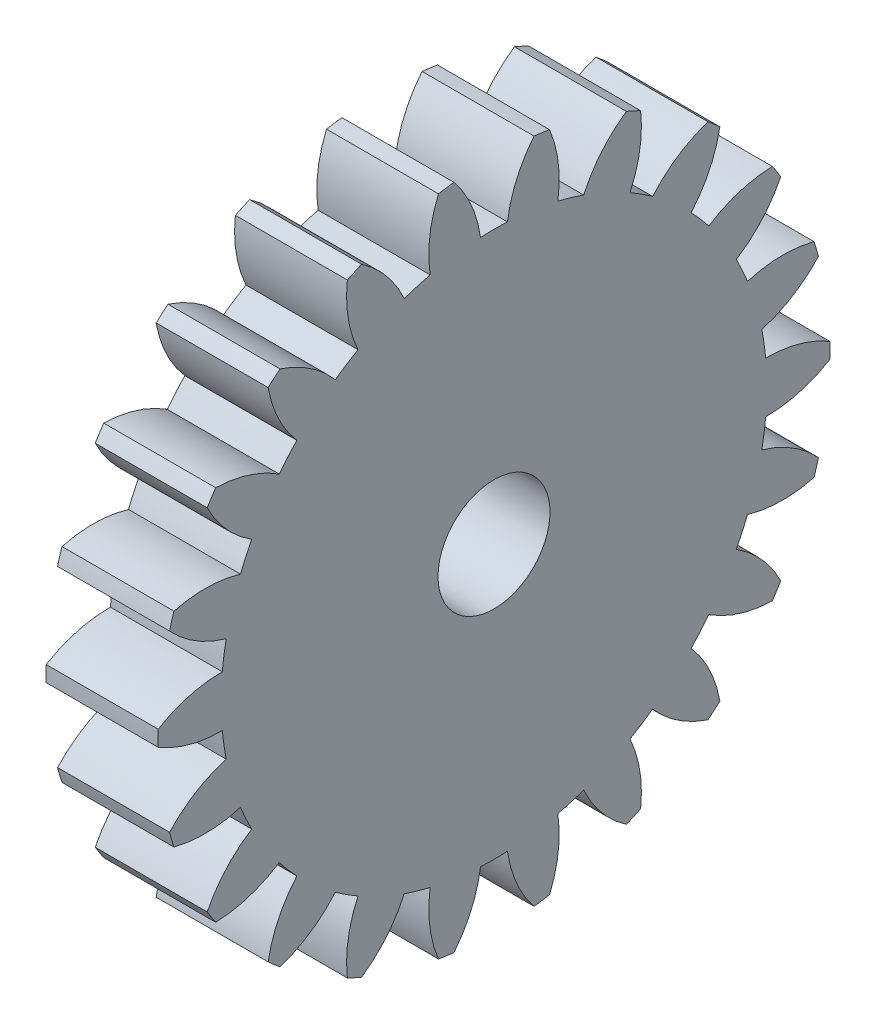
from build123d import *

# Parameters (mm, degrees)
BASPROSKE_W     = 1
BASPROSKE_H     = 3
TOOTHCUT_DEPTH  = 5.358898944
TEETHCUTS_COUNT = 22
TEETHCUTS_ANGLE = 343.636363636
BORSKE_R        = 0.5
BORE_DEPTH      = 50.0000508


with BuildPart() as part:
    # BasProSke → Base-Revolve (revolve)
    with BuildSketch(Plane(origin=(0, 0, 0), x_dir=(1, 0, 0), z_dir=(0, 1, 0)), mode=Mode.PRIVATE) as base_revolve_sk:
        with Locations((0.5, 1.5)):
            Rectangle(BASPROSKE_W, BASPROSKE_H)
    revolve(base_revolve_sk.sketch.rotate(Axis((-10, 0, 0), (1, 0, 0)), 180), axis=Axis((-10, 0, 0), (1, 0, 0)))

    # TooCutSke → ToothCut (cut, through all)
    with BuildSketch(Plane(origin=(0, 0, 0), x_dir=(0, 0, -1), z_dir=(1, 0, 0))):
        with BuildLine():
            ThreePointArc((0.120318822, 2.433527405), (0, 2.4365), (-0.120318822, 2.433527405))
            ThreePointArc((-0.120318822, 2.433527405), (-0.207576962, 2.736243526), (-0.37706112, 3.001811132))
            ThreePointArc((-0.37706112, 3.001811132), (0, 3.0254), (0.37706112, 3.001811132))
            ThreePointArc((0.37706112, 3.001811132), (0.207576962, 2.736243526), (0.120318822, 2.433527405))
        make_face()
    toothcut = extrude(amount=TOOTHCUT_DEPTH, mode=Mode.SUBTRACT)

    # TeethCuts: ToothCut ×22 about axis
    teethcuts_axis = Axis((-10, 0, 0), (1, 0, 0))
    for i in range(1, TEETHCUTS_COUNT):
        add(toothcut.rotate(teethcuts_axis, i * TEETHCUTS_ANGLE / (TEETHCUTS_COUNT - 1)), mode=Mode.SUBTRACT)

    # BorSke → Bore (cut, symmetric)
    with BuildSketch(Plane(origin=(0, 0, 0), x_dir=(0, 0, -1), z_dir=(1, 0, 0))):
        with Locations(Location((0, 0, 0), (0, 0, 180))):
            Circle(BORSKE_R)
    extrude(amount=BORE_DEPTH, both=True, mode=Mode.SUBTRACT)


solid = part.part
